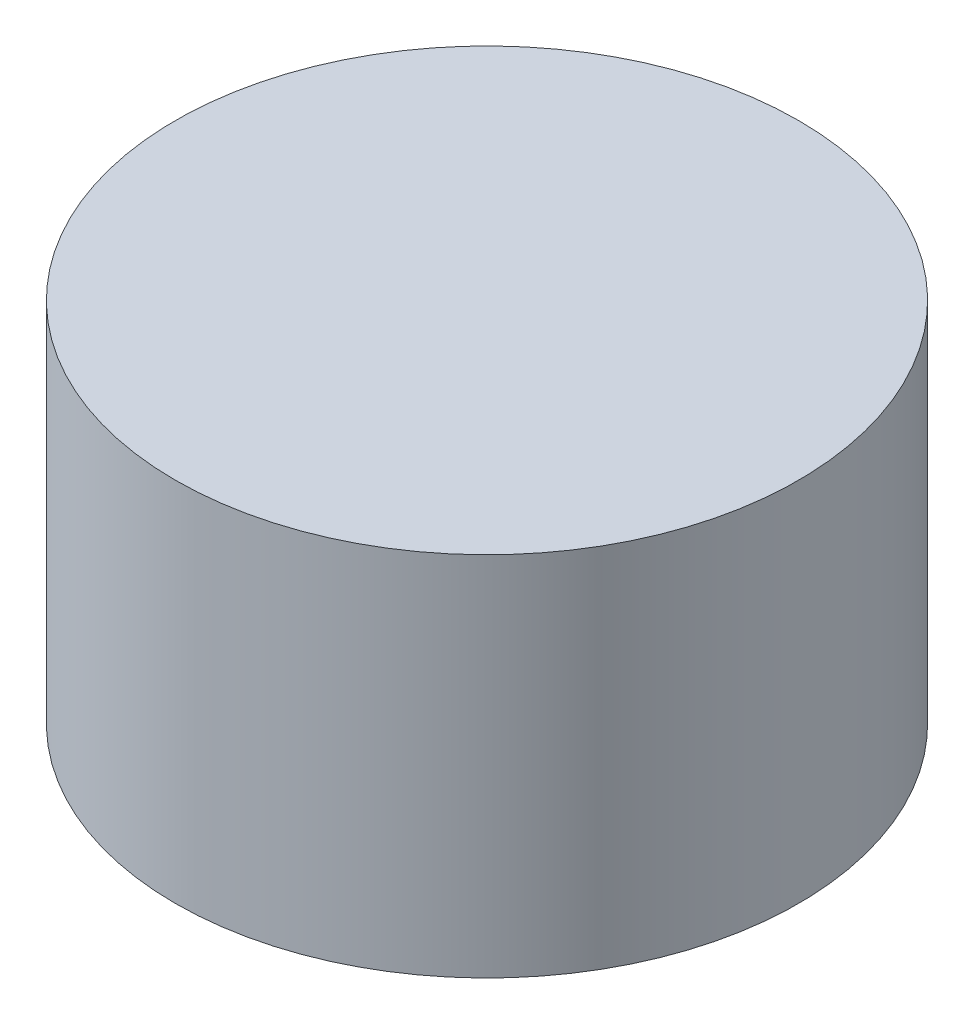
from build123d import *

# Parameters (mm, degrees)
SKETCH2_R           = 10.795
BOSS_EXTRUDE1_DEPTH = 12.7


with BuildPart() as part:
    # Sketch2 → Boss-Extrude1 (new body)
    with BuildSketch(Plane(origin=(0, 0, 0), x_dir=(1, 0, 0), z_dir=(0, 1, 0))):
        Circle(SKETCH2_R)
    extrude(amount=BOSS_EXTRUDE1_DEPTH)


solid = part.part
